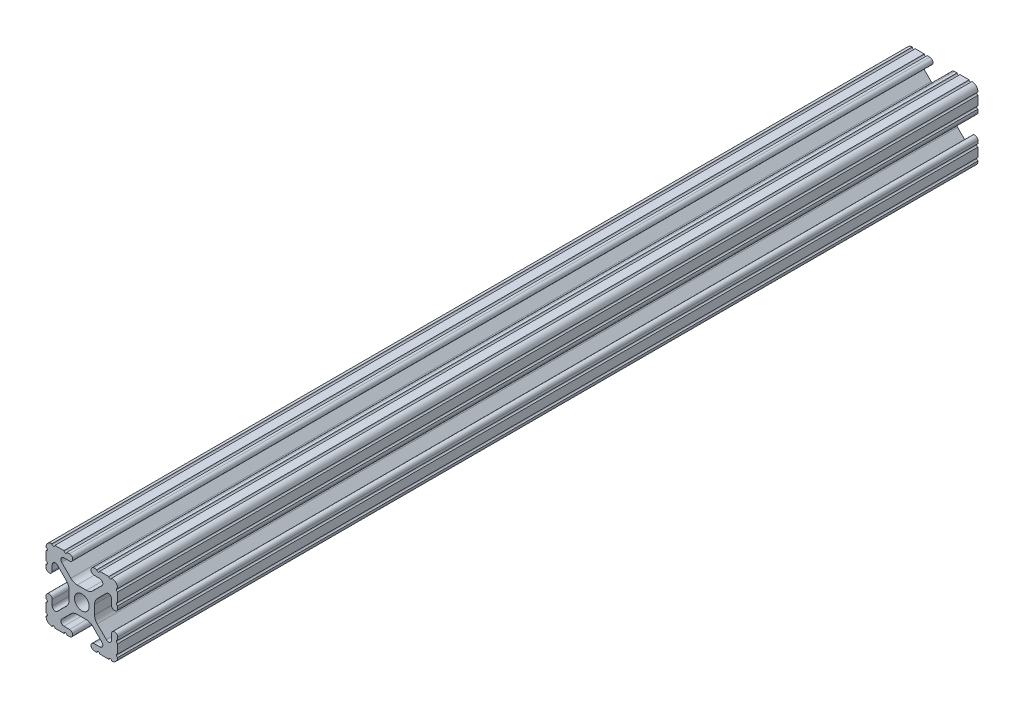
from build123d import *

# Parameters (mm, degrees)
SKETCH11_R              = 2.6035
FRACTIONAL_1010_1_DEPTH = 304.8


with BuildPart() as part:
    # Sketch11 → Fractional 1010(1) (new body)
    with BuildSketch(Plane.YX.offset(-152.4)):
        with BuildLine():
            Line((10.5918, 12.7), (10.5664, 12.7))
            ThreePointArc((10.5664, 12.7), (10.0584, 12.192), (9.5504, 12.7))
            Line((9.5504, 12.7), (6.3246, 12.7))
            ThreePointArc((6.3246, 12.7), (5.8166, 12.192), (5.3086, 12.7))
            Line((5.3086, 12.7), (4.3561, 12.7))
            ThreePointArc((4.3561, 12.7), (3.2512, 11.5951), (4.3561, 10.4902))
            Line((4.3561, 10.4902), (6.370083786, 10.4902))
            ThreePointArc((6.370083786, 10.4902), (7.348856743, 9.836204819), (7.119204175, 8.681663397))
            Line((7.119204175, 8.681663397), (3.88464389, 5.447103113))
            ThreePointArc((3.88464389, 5.447103113), (2.854599758, 4.758849627), (1.63957986, 4.517167143))
            Line((1.63957986, 4.517167143), (-1.63957986, 4.517167143))
            ThreePointArc((-1.63957986, 4.517167143), (-2.854599758, 4.758849627), (-3.88464389, 5.447103113))
            Line((-3.88464389, 5.447103113), (-7.119204175, 8.681663397))
            ThreePointArc((-7.119204175, 8.681663397), (-7.348856743, 9.836204819), (-6.370083786, 10.4902))
            Line((-6.370083786, 10.4902), (-4.3561, 10.4902))
            ThreePointArc((-4.3561, 10.4902), (-3.2512, 11.5951), (-4.3561, 12.7))
            Line((-4.3561, 12.7), (-5.3086, 12.7))
            ThreePointArc((-5.3086, 12.7), (-5.8166, 12.192), (-6.3246, 12.7))
            Line((-6.3246, 12.7), (-9.5504, 12.7))
            ThreePointArc((-9.5504, 12.7), (-10.0584, 12.192), (-10.5664, 12.7))
            Line((-10.5664, 12.7), (-10.5918, 12.7))
            ThreePointArc((-10.5918, 12.7), (-12.082522516, 12.082522516), (-12.7, 10.5918))
            Line((-12.7, 10.5918), (-12.7, 10.5664))
            ThreePointArc((-12.7, 10.5664), (-12.192, 10.0584), (-12.7, 9.5504))
            Line((-12.7, 9.5504), (-12.7, 6.3246))
            ThreePointArc((-12.7, 6.3246), (-12.192, 5.8166), (-12.7, 5.3086))
            Line((-12.7, 5.3086), (-12.7, 4.3561))
            ThreePointArc((-12.7, 4.3561), (-11.5951, 3.2512), (-10.4902, 4.3561))
            Line((-10.4902, 4.3561), (-10.4902, 6.370083786))
            ThreePointArc((-10.4902, 6.370083786), (-9.836204819, 7.348856743), (-8.681663397, 7.119204175))
            Line((-8.681663397, 7.119204175), (-5.447103113, 3.88464389))
            ThreePointArc((-5.447103113, 3.88464389), (-4.758849627, 2.854599758), (-4.517167143, 1.63957986))
            Line((-4.517167143, 1.63957986), (-4.517167143, -1.63957986))
            ThreePointArc((-4.517167143, -1.63957986), (-4.758849627, -2.854599758), (-5.447103113, -3.88464389))
            Line((-5.447103113, -3.88464389), (-8.681663397, -7.119204175))
            ThreePointArc((-8.681663397, -7.119204175), (-9.836204819, -7.348856743), (-10.4902, -6.370083786))
            Line((-10.4902, -6.370083786), (-10.4902, -4.3561))
            ThreePointArc((-10.4902, -4.3561), (-11.5951, -3.2512), (-12.7, -4.3561))
            Line((-12.7, -4.3561), (-12.7, -5.3086))
            ThreePointArc((-12.7, -5.3086), (-12.192, -5.8166), (-12.7, -6.3246))
            Line((-12.7, -6.3246), (-12.7, -9.5504))
            ThreePointArc((-12.7, -9.5504), (-12.192, -10.0584), (-12.7, -10.5664))
            Line((-12.7, -10.5664), (-12.7, -10.5918))
            ThreePointArc((-12.7, -10.5918), (-12.082522516, -12.082522516), (-10.5918, -12.7))
            Line((-10.5918, -12.7), (-10.5664, -12.7))
            ThreePointArc((-10.5664, -12.7), (-10.0584, -12.192), (-9.5504, -12.7))
            Line((-9.5504, -12.7), (-6.3246, -12.7))
            ThreePointArc((-6.3246, -12.7), (-5.8166, -12.192), (-5.3086, -12.7))
            Line((-5.3086, -12.7), (-4.3561, -12.7))
            ThreePointArc((-4.3561, -12.7), (-3.2512, -11.5951), (-4.3561, -10.4902))
            Line((-4.3561, -10.4902), (-6.370083786, -10.4902))
            ThreePointArc((-6.370083786, -10.4902), (-7.348856743, -9.836204819), (-7.119204175, -8.681663397))
            Line((-7.119204175, -8.681663397), (-3.88464389, -5.447103113))
            ThreePointArc((-3.88464389, -5.447103113), (-2.854599758, -4.758849627), (-1.63957986, -4.517167143))
            Line((-1.63957986, -4.517167143), (1.63957986, -4.517167143))
            ThreePointArc((1.63957986, -4.517167143), (2.854599758, -4.758849627), (3.88464389, -5.447103113))
            Line((3.88464389, -5.447103113), (7.119204175, -8.681663397))
            ThreePointArc((7.119204175, -8.681663397), (7.348856743, -9.836204819), (6.370083786, -10.4902))
            Line((6.370083786, -10.4902), (4.3561, -10.4902))
            ThreePointArc((4.3561, -10.4902), (3.2512, -11.5951), (4.3561, -12.7))
            Line((4.3561, -12.7), (5.3086, -12.7))
            ThreePointArc((5.3086, -12.7), (5.8166, -12.192), (6.3246, -12.7))
            Line((6.3246, -12.7), (9.5504, -12.7))
            ThreePointArc((9.5504, -12.7), (10.0584, -12.192), (10.5664, -12.7))
            Line((10.5664, -12.7), (10.5918, -12.7))
            ThreePointArc((10.5918, -12.7), (12.082522516, -12.082522516), (12.7, -10.5918))
            Line((12.7, -10.5918), (12.7, -10.5664))
            ThreePointArc((12.7, -10.5664), (12.192, -10.0584), (12.7, -9.5504))
            Line((12.7, -9.5504), (12.7, -6.3246))
            ThreePointArc((12.7, -6.3246), (12.192, -5.8166), (12.7, -5.3086))
            Line((12.7, -5.3086), (12.7, -4.3561))
            ThreePointArc((12.7, -4.3561), (11.5951, -3.2512), (10.4902, -4.3561))
            Line((10.4902, -4.3561), (10.4902, -6.370083786))
            ThreePointArc((10.4902, -6.370083786), (9.836204819, -7.348856743), (8.681663397, -7.119204175))
            Line((8.681663397, -7.119204175), (5.447103113, -3.88464389))
            ThreePointArc((5.447103113, -3.88464389), (4.758849627, -2.854599758), (4.517167143, -1.63957986))
            Line((4.517167143, -1.63957986), (4.517167143, 1.63957986))
            ThreePointArc((4.517167143, 1.63957986), (4.758849627, 2.854599758), (5.447103113, 3.88464389))
            Line((5.447103113, 3.88464389), (8.681663397, 7.119204175))
            ThreePointArc((8.681663397, 7.119204175), (9.836204819, 7.348856743), (10.4902, 6.370083786))
            Line((10.4902, 6.370083786), (10.4902, 4.3561))
            ThreePointArc((10.4902, 4.3561), (11.5951, 3.2512), (12.7, 4.3561))
            Line((12.7, 4.3561), (12.7, 5.3086))
            ThreePointArc((12.7, 5.3086), (12.192, 5.8166), (12.7, 6.3246))
            Line((12.7, 6.3246), (12.7, 9.5504))
            ThreePointArc((12.7, 9.5504), (12.192, 10.0584), (12.7, 10.5664))
            Line((12.7, 10.5664), (12.7, 10.5918))
            ThreePointArc((12.7, 10.5918), (12.082522516, 12.082522516), (10.5918, 12.7))
        make_face()
        Circle(SKETCH11_R, mode=Mode.SUBTRACT)
    extrude(amount=FRACTIONAL_1010_1_DEPTH)


solid = part.part
